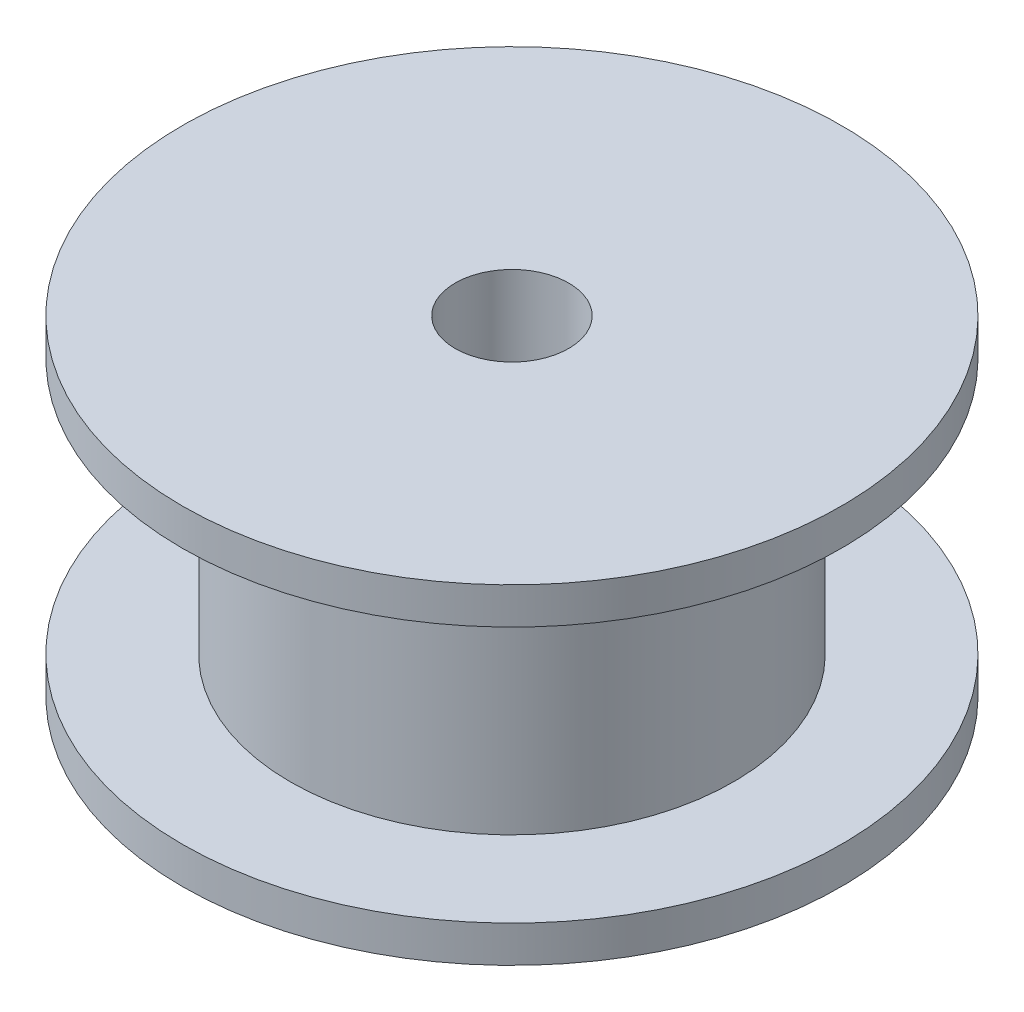
from build123d import *

# Parameters (mm, degrees)
CROQUIS1_R              = 9
CROQUIS1_R_2            = 1.55
SALIENTE_EXTRUIR1_DEPTH = 1
CROQUIS1_3_R            = 6.05
CROQUIS1_3_R_2          = 1.55
SALIENTE_EXTRUIR2_DEPTH = 8
CROQUIS2_R              = 9
CROQUIS2_R_2            = 1.55
SALIENTE_EXTRUIR3_DEPTH = 1


with BuildPart() as part:
    # Croquis1 → Saliente-Extruir1 (new body)
    with BuildSketch(Plane(origin=(0, 0, 0), x_dir=(1, 0, 0), z_dir=(0, 1, 0))):
        Circle(CROQUIS1_R)
        Circle(CROQUIS1_R_2, mode=Mode.SUBTRACT)
    extrude(amount=SALIENTE_EXTRUIR1_DEPTH)

    # Croquis1_3 → Saliente-Extruir2 (add)
    with BuildSketch(Plane(origin=(0, 0, 0), x_dir=(1, 0, 0), z_dir=(0, 1, 0))):
        Circle(CROQUIS1_3_R)
        Circle(CROQUIS1_3_R_2, mode=Mode.SUBTRACT)
    extrude(amount=SALIENTE_EXTRUIR2_DEPTH)

    # Croquis2 → Saliente-Extruir3 (add)
    with BuildSketch(Plane(origin=(0, 8, 0), x_dir=(1, 0, 0), z_dir=(0, 1, 0))):
        Circle(CROQUIS2_R)
        Circle(CROQUIS2_R_2, mode=Mode.SUBTRACT)
    extrude(amount=SALIENTE_EXTRUIR3_DEPTH)


solid = part.part
